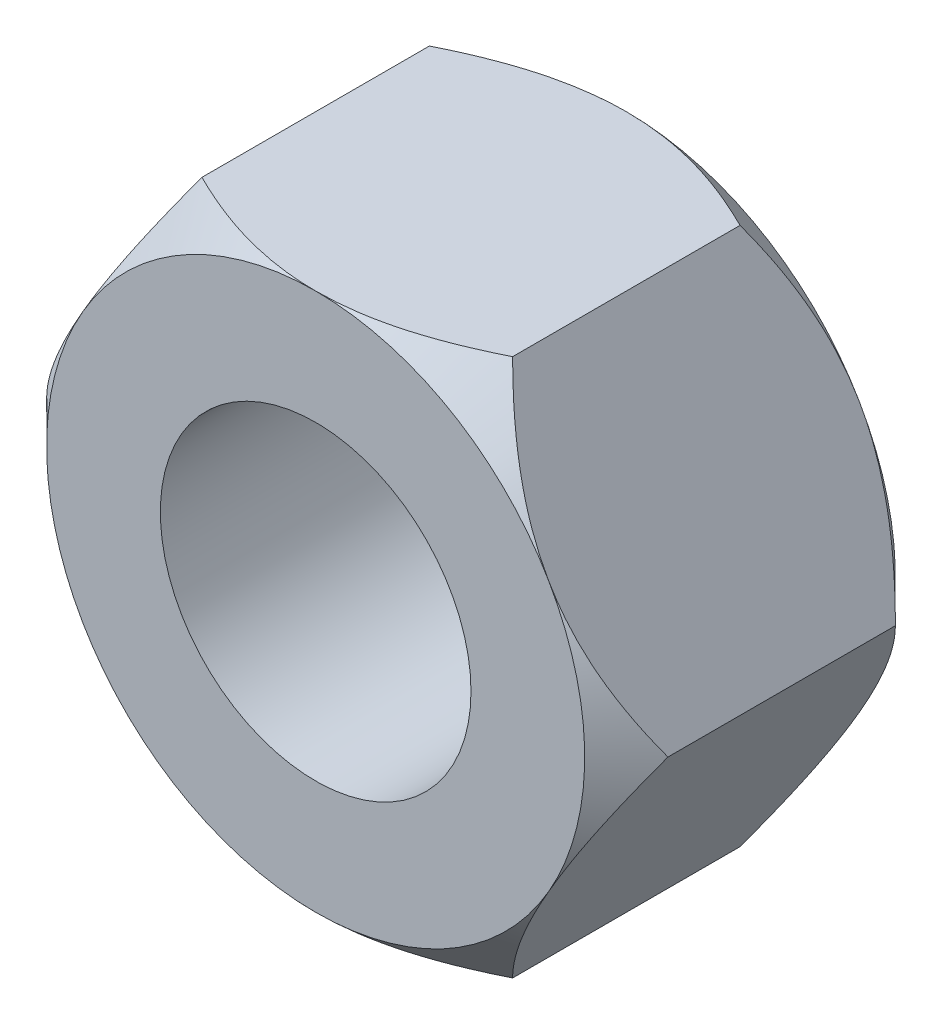
from build123d import *

# Parameters (mm, degrees)
SKETCH1_R           = 4.5
BOSS_EXTRUDE3_DEPTH = 4.5
SKETCH3_OUTSIDE_W   = 43.092
SKETCH3_OUTSIDE_H   = 40.68
SKETCH3_OUTSIDE_R   = 7.794228634
CUT_EXTRUDE5_DEPTH  = 9
CUT_EXTRUDE5_TAPER  = 45


with BuildPart() as part:
    # Sketch1 → Boss-Extrude3 (new body, symmetric)
    with BuildSketch(Plane.XY):
        Polygon((9, 0), (4.5, 7.794228634), (-4.5, 7.794228634), (-9, 0), (-4.5, -7.794228634), (4.5, -7.794228634), align=None)
        Circle(SKETCH1_R, mode=Mode.SUBTRACT)
    extrude(amount=BOSS_EXTRUDE3_DEPTH, both=True)

    # Sketch3 outside → Cut-Extrude5 (cut)
    with BuildSketch(Plane.XY.offset(4.5)):
        Rectangle(SKETCH3_OUTSIDE_W, SKETCH3_OUTSIDE_H)
        Circle(SKETCH3_OUTSIDE_R, mode=Mode.SUBTRACT)
    cut_extrude5 = extrude(amount=-CUT_EXTRUDE5_DEPTH, taper=CUT_EXTRUDE5_TAPER, mode=Mode.SUBTRACT)

    # Mirror2: Cut-Extrude5 across plane
    add(cut_extrude5.mirror(Plane.XY), mode=Mode.SUBTRACT)


solid = part.part
